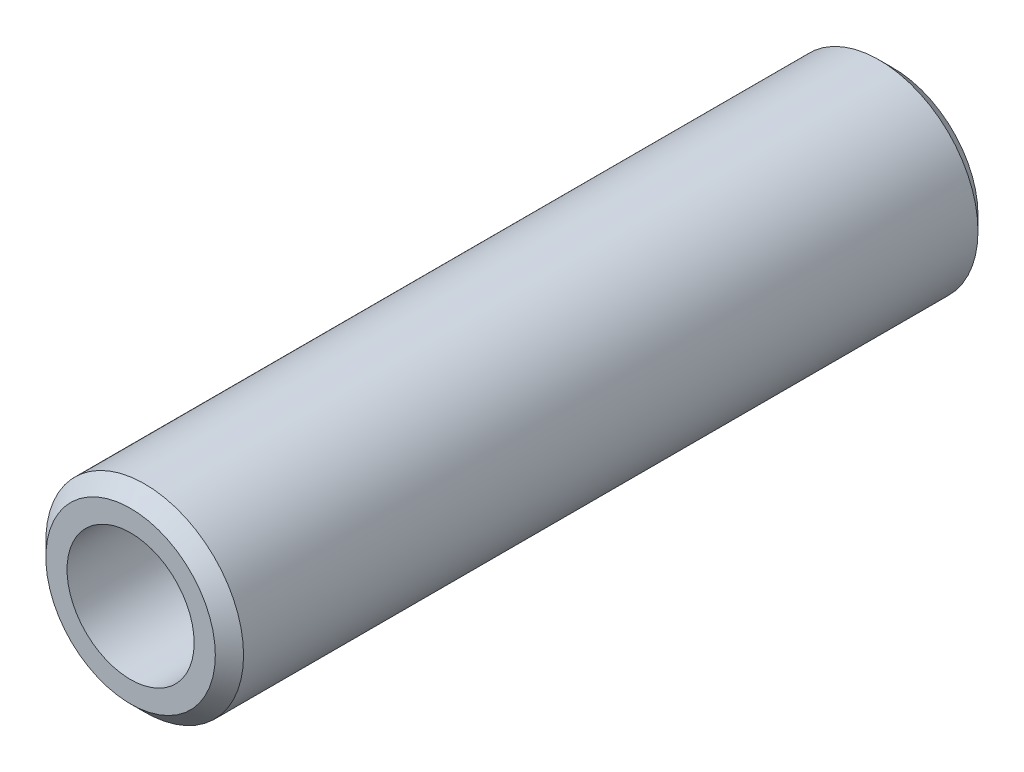
from build123d import *

# Parameters (mm, degrees)
ESQUISSE1_R        = 3.5
ESQUISSE1_R_2      = 2.25
BOSS_EXTRU_1_DEPTH = 13.5
CHANFREIN1_SIZE    = 0.5


with BuildPart() as part:
    # Esquisse1 → Boss.-Extru.1 (new body, symmetric)
    with BuildSketch(Plane.XY):
        Circle(ESQUISSE1_R)
        Circle(ESQUISSE1_R_2, mode=Mode.SUBTRACT)
    extrude(amount=BOSS_EXTRU_1_DEPTH, both=True)

    # Chanfrein1
    chanfrein1_edges = [part.edges().sort_by_distance(p)[0] for p in [
        (-3.5, 0, -13.5),
        (-3.5, 0, 13.5),
    ]]
    chamfer(chanfrein1_edges, length=CHANFREIN1_SIZE)


solid = part.part
